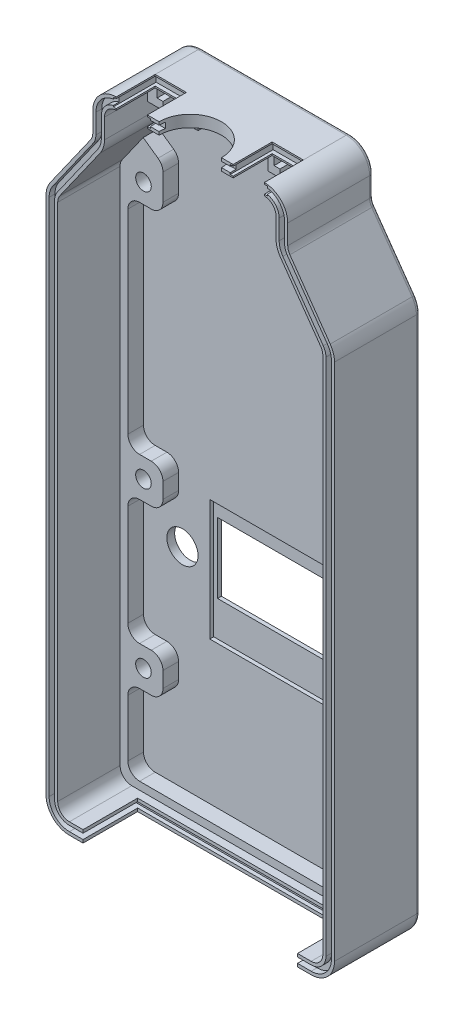
from build123d import *

# Parameters (mm, degrees)
SKETCH3_W           = 74
SKETCH3_H           = 170
BOSS_EXTRUDE1_DEPTH = 2
CUT_EXTRUDE1_DEPTH  = 2
BOSS_EXTRUDE2_DEPTH = 20
SKETCH6_R           = 2
BOSS_EXTRUDE3_DEPTH = 4
FILLET1_R           = 3
FILLET2_R           = 6
FILLET3_R           = 3
FILLET4_R           = 1
SKETCH7_R           = 4
CUT_EXTRUDE2_DEPTH  = 2
SKETCH8_W           = 28
SKETCH8_H           = 18
CUT_EXTRUDE8_DEPTH  = 2
SKETCH9_W           = 30
SKETCH9_H           = 31
CUT_EXTRUDE9_DEPTH  = 1
CUT_EXTRUDE13_DEPTH = 1.5
SKETCH10_R          = 8
CUT_EXTRUDE10_DEPTH = 3
SKETCH11_W          = 8
SKETCH11_H          = 3
CUT_EXTRUDE11_DEPTH = 10
SKETCH16_W          = 13
SKETCH16_H          = 5
BOSS_EXTRUDE5_DEPTH = 5
BOSS_EXTRUDE4_DEPTH = 4
SKETCH13_W          = 9.5
SKETCH13_H          = 2.2
CUT_EXTRUDE12_DEPTH = 11
CUT_EXTRUDE14_DEPTH = 14
FILLET5_R           = 3
SKETCH17_W          = 58
SKETCH17_H          = 1.4
CUT_EXTRUDE15_DEPTH = 1


with BuildPart() as part:
    # Sketch3 → Boss-Extrude1 (new body)
    with BuildSketch(Plane.XY):
        Rectangle(SKETCH3_W, SKETCH3_H)
    extrude(amount=BOSS_EXTRUDE1_DEPTH)

    # Sketch4 → Cut-Extrude1 (cut)
    with BuildSketch(Plane.XY.offset(2)):
        Polygon((-25, 73), (-37, 56), (-37, 85), (-25, 85), align=None)
        Polygon((25, 73), (37, 56), (37, 85), (25, 85), align=None)
    extrude(amount=-CUT_EXTRUDE1_DEPTH, mode=Mode.SUBTRACT)

    # Sketch5 → Boss-Extrude2 (add)
    with BuildSketch(Plane.XY.offset(2)):
        Polygon((-25, 85), (25, 85), (25, 73), (37, 56), (37, -85), (-37, -85), (-37, 56), (-25, 73), align=None)
        Polygon((-22, 82), (22, 82), (22, 72.047836988), (34, 55.047836988), (34, -82), (-34, -82), (-34, 55.047836988), (-22, 72.047836988), align=None, mode=Mode.SUBTRACT)
    extrude(amount=BOSS_EXTRUDE2_DEPTH)

    # Sketch6 → Boss-Extrude3 (add)
    with BuildSketch(Plane.XY.offset(2)):
        Polygon((34, -82), (34, 55.047836988), (28.076284032, 63.439767943), (23, 59.856508626), (23, 48.593613546), (32, 48.593613546), (32, -7.406386454), (23, -7.406386454), (23, -17.406386454), (32, -17.406386454), (32, -49.406386454), (23, -49.406386454), (23, -59.406386454), (32, -59.406386454), (32, -80), (-32, -80), (-32, -59.406386454), (-23, -59.406386454), (-23, -49.406386454), (-32, -49.406386454), (-32, -17.406386454), (-23, -17.406386454), (-23, -7.406386454), (-32, -7.406386454), (-32, 48.593613546), (-23, 48.593613546), (-23, 59.856508626), (-28.076284032, 63.439767943), (-34, 55.047836988), (-34, -82), align=None)
        with Locations((28, -54.406386454)):
            Circle(SKETCH6_R, mode=Mode.SUBTRACT)
        with Locations((-28, -54.406386454)):
            Circle(SKETCH6_R, mode=Mode.SUBTRACT)
        with Locations((28, -12.406386454)):
            Circle(SKETCH6_R, mode=Mode.SUBTRACT)
        with Locations((-28, -12.406386454)):
            Circle(SKETCH6_R, mode=Mode.SUBTRACT)
        with Locations((-28, 53.593613546)):
            Circle(SKETCH6_R, mode=Mode.SUBTRACT)
        with Locations((28, 53.593613546)):
            Circle(SKETCH6_R, mode=Mode.SUBTRACT)
    extrude(amount=BOSS_EXTRUDE3_DEPTH)

    # Fillet1
    fillet1_edges = [part.edges().sort_by_distance(p)[0] for p in [
        (23, 59.856508626, 4),
        (23, 48.593613546, 4),
        (32, 48.593613546, 4),
        (32, -7.406386454, 4),
        (23, -7.406386454, 4),
        (23, -17.406386454, 4),
        (32, -17.406386454, 4),
        (32, -49.406386454, 4),
        (23, -49.406386454, 4),
        (23, -59.406386454, 4),
        (32, -59.406386454, 4),
        (32, -80, 4),
        (-32, -80, 4),
        (-32, -59.406386454, 4),
        (-23, -59.406386454, 4),
        (-23, -49.406386454, 4),
        (-32, -49.406386454, 4),
        (-32, -17.406386454, 4),
        (-23, -17.406386454, 4),
        (-23, -7.406386454, 4),
        (-32, -7.406386454, 4),
        (-32, 48.593613546, 4),
        (-23, 48.593613546, 4),
        (-23, 59.856508626, 4),
    ]]
    fillet(fillet1_edges, radius=FILLET1_R)

    # Fillet2
    fillet2_edges = [part.edges().sort_by_distance(p)[0] for p in [
        (-37, 56, 11),
        (-25, 85, 11),
        (37, 56, 11),
        (25, 85, 11),
        (22, 72.047836988, 12),
        (-22, 72.047836988, 12),
        (37, -85, 11),
        (-37, -85, 11),
    ]]
    fillet(fillet2_edges, radius=FILLET2_R)

    # Fillet3
    fillet3_edges = [part.edges().sort_by_distance(p)[0] for p in [
        (-25, 73, 11),
        (25, 73, 11),
        (-34, 55.047836988, 14),
        (-34, -82, 14),
        (34, -82, 14),
        (34, 55.047836988, 14),
        (22, 82, 12),
        (-22, 82, 12),
    ]]
    fillet(fillet3_edges, radius=FILLET3_R)

    # Fillet4
    fillet4_edges = [part.edges().sort_by_distance(p)[0] for p in [
        (37, -12.452163012, 0),
        (-30.725451795, 64.888943291, 0),
        (0, 85, 0),
        (25, 76.476081506, 0),
        (0, -85, 0),
        (-37, -12.452163012, 0),
        (-23.242640687, 83.242640687, 0),
        (23.242640687, 83.242640687, 0),
        (36.718865407, 55.910771346, 0),
        (-36.718865407, 55.910771346, 0),
        (-35.242640687, -83.242640687, 0),
        (35.242640687, -83.242640687, 0),
        (30.725451795, 64.888943291, 0),
        (-25, 76.476081506, 0),
        (25.140567297, 73.044614327, 0),
        (-25.140567297, 73.044614327, 0),
    ]]
    fillet(fillet4_edges, radius=FILLET4_R)

    # Sketch7 → Cut-Extrude2 (cut)
    with BuildSketch(Plane.XY.offset(2)):
        with Locations((-22, -26.406386454)):
            Circle(SKETCH7_R)
        with Locations((22, -26.406386454)):
            Circle(SKETCH7_R)
    extrude(amount=-CUT_EXTRUDE2_DEPTH, mode=Mode.SUBTRACT)

    # Sketch8 → Cut-Extrude8 (cut)
    with BuildSketch(Plane.XY.offset(2)):
        with Locations((0, -25.406386454)):
            Rectangle(SKETCH8_W, SKETCH8_H)
    extrude(amount=-CUT_EXTRUDE8_DEPTH, mode=Mode.SUBTRACT)

    # Sketch9 → Cut-Extrude9 (cut)
    with BuildSketch(Plane.XY.offset(2)):
        with Locations((0, -27.906386454)):
            Rectangle(SKETCH9_W, SKETCH9_H)
    extrude(amount=-CUT_EXTRUDE9_DEPTH, mode=Mode.SUBTRACT)

    # Sketch14 → Cut-Extrude13 (cut)
    with BuildSketch(Plane.XY.offset(22)):
        with BuildLine():
            Line((-19, 84.2), (19, 84.2))
            ThreePointArc((19, 84.2), (22.676955262, 82.676955262), (24.2, 79))
            Line((24.2, 79), (24.2, 73.952163012))
            ThreePointArc((24.2, 73.952163012), (24.378051909, 72.802601344), (24.89552212, 71.760766861))
            Line((24.89552212, 71.760766861), (35.248232889, 57.094426604))
            ThreePointArc((35.248232889, 57.094426604), (35.956350019, 55.668758364), (36.2, 54.095673977))
            Line((36.2, 54.095673977), (36.2, -79))
            ThreePointArc((36.2, -79), (34.676955262, -82.676955262), (31, -84.2))
            Line((31, -84.2), (-31, -84.2))
            ThreePointArc((-31, -84.2), (-34.676955262, -82.676955262), (-36.2, -79))
            Line((-36.2, -79), (-36.2, 54.095673977))
            ThreePointArc((-36.2, 54.095673977), (-35.956350019, 55.668758364), (-35.248232889, 57.094426604))
            Line((-35.248232889, 57.094426604), (-24.89552212, 71.760766861))
            ThreePointArc((-24.89552212, 71.760766861), (-24.378051909, 72.802601344), (-24.2, 73.952163012))
            Line((-24.2, 73.952163012), (-24.2, 79))
            ThreePointArc((-24.2, 79), (-22.676955262, 82.676955262), (-19, 84.2))
        make_face()
        with BuildLine():
            Line((-19, 82.8), (19, 82.8))
            ThreePointArc((19, 82.8), (21.687005769, 81.687005769), (22.8, 79))
            Line((22.8, 79), (22.8, 73.952163012))
            ThreePointArc((22.8, 73.952163012), (23.043649981, 72.379078625), (23.751767111, 70.953410384))
            Line((23.751767111, 70.953410384), (34.10447788, 56.287070128))
            ThreePointArc((34.10447788, 56.287070128), (34.621948091, 55.245235644), (34.8, 54.095673977))
            Line((34.8, 54.095673977), (34.8, -79))
            ThreePointArc((34.8, -79), (33.687005769, -81.687005769), (31, -82.8))
            Line((31, -82.8), (-31, -82.8))
            ThreePointArc((-31, -82.8), (-33.687005769, -81.687005769), (-34.8, -79))
            Line((-34.8, -79), (-34.8, 54.095673977))
            ThreePointArc((-34.8, 54.095673977), (-34.621948091, 55.245235644), (-34.10447788, 56.287070128))
            Line((-34.10447788, 56.287070128), (-23.751767111, 70.953410384))
            ThreePointArc((-23.751767111, 70.953410384), (-23.043649981, 72.379078625), (-22.8, 73.952163012))
            Line((-22.8, 73.952163012), (-22.8, 79))
            ThreePointArc((-22.8, 79), (-21.687005769, 81.687005769), (-19, 82.8))
        make_face(mode=Mode.SUBTRACT)
    extrude(amount=-CUT_EXTRUDE13_DEPTH, mode=Mode.SUBTRACT)

    # Sketch10 → Cut-Extrude10 (cut)
    with BuildSketch(Plane.XZ.offset(-82)):
        with Locations((0, 22)):
            Circle(SKETCH10_R)
    extrude(amount=-CUT_EXTRUDE10_DEPTH, mode=Mode.SUBTRACT)

    # Sketch11 → Cut-Extrude11 (cut)
    with BuildSketch(Plane.XY.offset(22)):
        with Locations((-15, 83.5)):
            Rectangle(SKETCH11_W, SKETCH11_H)
        with Locations((15, 83.5)):
            Rectangle(SKETCH11_W, SKETCH11_H)
    extrude(amount=-CUT_EXTRUDE11_DEPTH, mode=Mode.SUBTRACT)

    # Sketch16 → Boss-Extrude5 (add)
    with BuildSketch(Plane.XY.offset(2)):
        with Locations((-15.5, 79.5)):
            Rectangle(SKETCH16_W, SKETCH16_H)
        with Locations((15.5, 79.5)):
            Rectangle(SKETCH16_W, SKETCH16_H)
    extrude(amount=BOSS_EXTRUDE5_DEPTH)

    # Sketch12 → Boss-Extrude4 (add)
    with BuildSketch(Plane.XY.offset(7)):
        Polygon((-22, 82), (-18, 82), (-18, 81), (-19.5, 81), (-19.5, 79), (-18, 79), (-18, 77), (-22, 77), align=None)
        Polygon((-12, 82), (-9, 82), (-9, 77), (-12, 77), (-12, 79), (-10.5, 79), (-10.5, 81), (-12, 81), align=None)
        Polygon((9, 82), (12, 82), (12, 81), (10.5, 81), (10.5, 79), (12, 79), (12, 77), (9, 77), align=None)
        Polygon((18, 82), (22, 82), (22, 77), (18, 77), (18, 79), (19.5, 79), (19.5, 81), (18, 81), align=None)
    extrude(amount=BOSS_EXTRUDE4_DEPTH)

    # Sketch13 → Cut-Extrude12 (cut)
    with BuildSketch(Plane.XY.offset(22)):
        with Locations((-15, 83.5)):
            Rectangle(SKETCH13_W, SKETCH13_H)
        with Locations((15, 83.5)):
            Rectangle(SKETCH13_W, SKETCH13_H)
    extrude(amount=-CUT_EXTRUDE12_DEPTH, mode=Mode.SUBTRACT)

    # Sketch15 → Cut-Extrude14 (cut)
    with BuildSketch(Plane.XY.offset(22)):
        Polygon((-27.5, -82), (-27.5, -82.8), (-29, -82.8), (-29, -84.2), (-27.5, -84.2), (-27.5, -85), (27.5, -85), (27.5, -84.2), (29, -84.2), (29, -82.8), (27.5, -82.8), (27.5, -82), align=None)
    extrude(amount=-CUT_EXTRUDE14_DEPTH, mode=Mode.SUBTRACT)

    # Fillet5
    fillet5_edges = [part.edges().sort_by_distance(p)[0] for p in [
        (-9, 79.5, 2),
        (9, 79.5, 2),
    ]]
    fillet(fillet5_edges, radius=FILLET5_R)

    # Sketch17 → Cut-Extrude15 (cut)
    with BuildSketch(Plane.XY.offset(8)):
        with Locations((0, -83.5)):
            Rectangle(SKETCH17_W, SKETCH17_H)
    extrude(amount=-CUT_EXTRUDE15_DEPTH, mode=Mode.SUBTRACT)


solid = part.part
